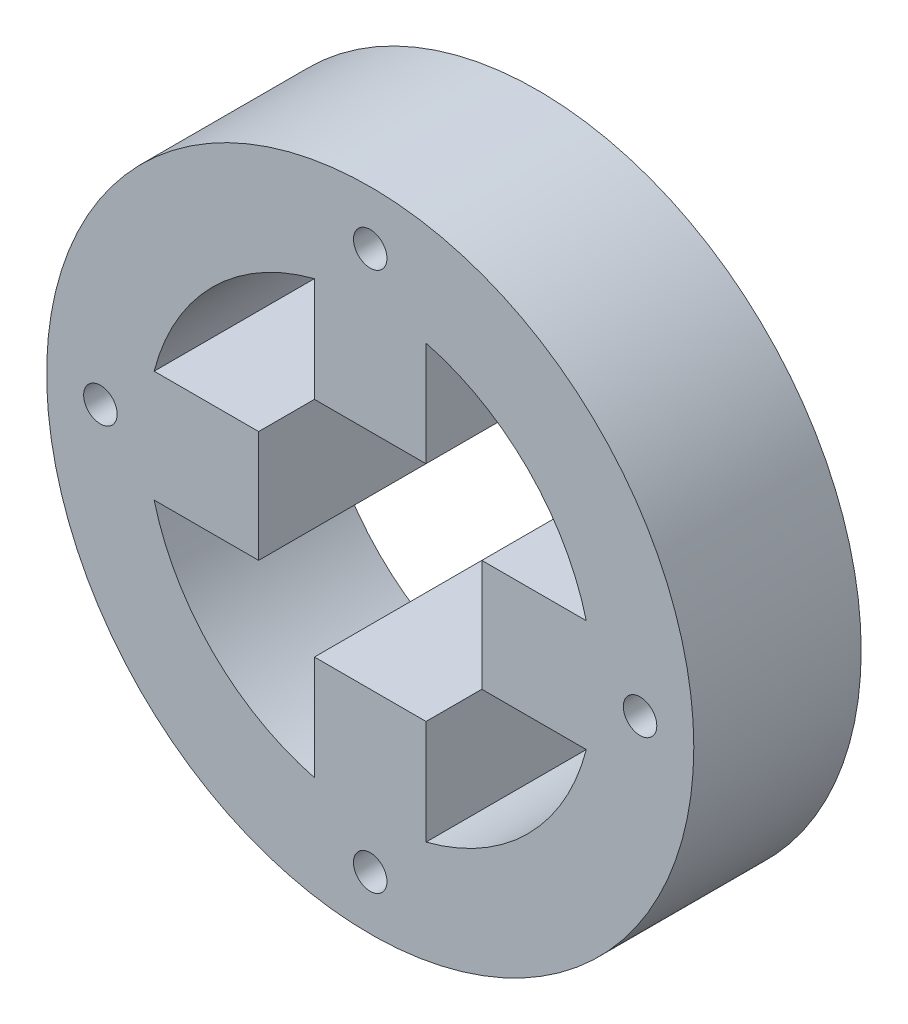
from build123d import *

# Parameters (mm, degrees)
SKETCH6_R                 = 29
SKETCH6_R_2               = 20
INNER_RING_DEPTH          = 15
MOTOR_CONNECTOR_CUT_DEPTH = 15
SKETCH8_R                 = 1.5
M3_HOLES_DEPTH            = 38
M3_HOLES_DEPTH_BACK       = 53


with BuildPart() as part:
    # Sketch6 → Inner Ring (new body)
    with BuildSketch(Plane.XY):
        Circle(SKETCH6_R)
        Circle(SKETCH6_R_2, mode=Mode.SUBTRACT)
    extrude(amount=-INNER_RING_DEPTH)

    # Sketch7 → Motor Connector Cut (add)
    with BuildSketch(Plane.XY):
        with BuildLine():
            ThreePointArc((20, 0), (19.840593925, 2.52008585), (19.364916731, 5))
            Line((19.364916731, 5), (9.999996731, 5))
            Line((9.999996731, 5), (9.999996731, -5))
            Line((9.999996731, -5), (19.364916731, -5))
            ThreePointArc((19.364916731, -5), (19.840593925, -2.52008585), (20, 0))
        make_face()
        with BuildLine():
            ThreePointArc((5, 19.364916731), (0, 20), (-5, 19.364916731))
            Line((-5, 19.364916731), (-5, 9.999996731))
            Line((-5, 9.999996731), (5, 9.999996731))
            Line((5, 9.999996731), (5, 19.364916731))
        make_face()
        with BuildLine():
            Line((-9.999996731, -5), (-9.999996731, 5))
            Line((-9.999996731, 5), (-19.364916731, 5))
            ThreePointArc((-19.364916731, 5), (-20, 0), (-19.364916731, -5))
            Line((-19.364916731, -5), (-9.999996731, -5))
        make_face()
        with BuildLine():
            Line((-5, -9.999996731), (-5, -19.364916731))
            ThreePointArc((-5, -19.364916731), (0, -20), (5, -19.364916731))
            Line((5, -19.364916731), (5, -9.999996731))
            Line((5, -9.999996731), (-5, -9.999996731))
        make_face()
    extrude(amount=-MOTOR_CONNECTOR_CUT_DEPTH)

    # Sketch8 → M3 Holes (cut, two sides)
    with BuildSketch(Plane.XY) as m3_holes_sk:
        with Locations((0, 24.182458366)):
            Circle(SKETCH8_R)
        with Locations((24.182458366, 0)):
            Circle(SKETCH8_R)
        with Locations((0, -24.182458366)):
            Circle(SKETCH8_R)
        with Locations((-24.182458366, 0)):
            Circle(SKETCH8_R)
    extrude(amount=M3_HOLES_DEPTH, mode=Mode.SUBTRACT)
    extrude(m3_holes_sk.sketch, amount=-M3_HOLES_DEPTH_BACK, mode=Mode.SUBTRACT)


solid = part.part
